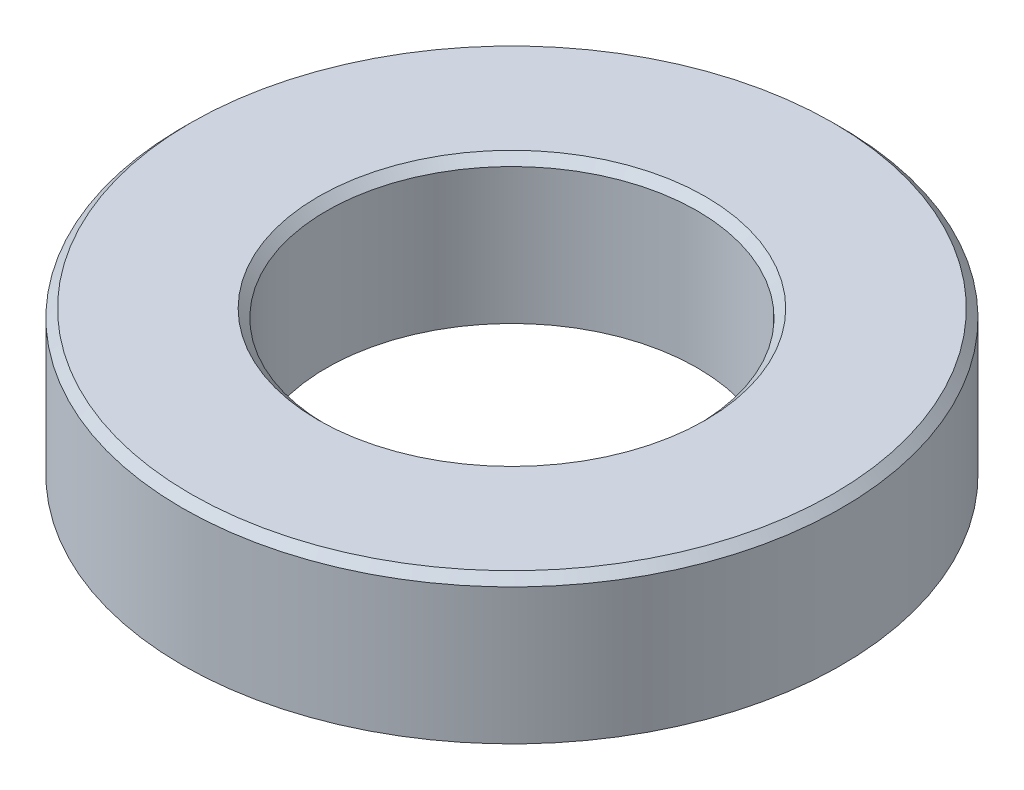
from build123d import *

# Parameters (mm, degrees)
SKETCH_1_R      = 8
SKETCH_1_R_2    = 4.5
EXTRUDE_1_DEPTH = 3.5
CHAMFER_1_SIZE  = 0.2


with BuildPart() as part:
    # 스케치1 → 보스-돌출1 (new body)
    with BuildSketch(Plane(origin=(0, 0, 0), x_dir=(1, 0, 0), z_dir=(0, 1, 0))):
        Circle(SKETCH_1_R)
        Circle(SKETCH_1_R_2, mode=Mode.SUBTRACT)
    extrude(amount=EXTRUDE_1_DEPTH)

    # 모따기1
    chamfer_1_edges = [part.edges().sort_by_distance(p)[0] for p in [
        (-8, 3.5, 0),
        (-4.5, 3.5, 0),
    ]]
    chamfer(chamfer_1_edges, length=CHAMFER_1_SIZE)


solid = part.part
